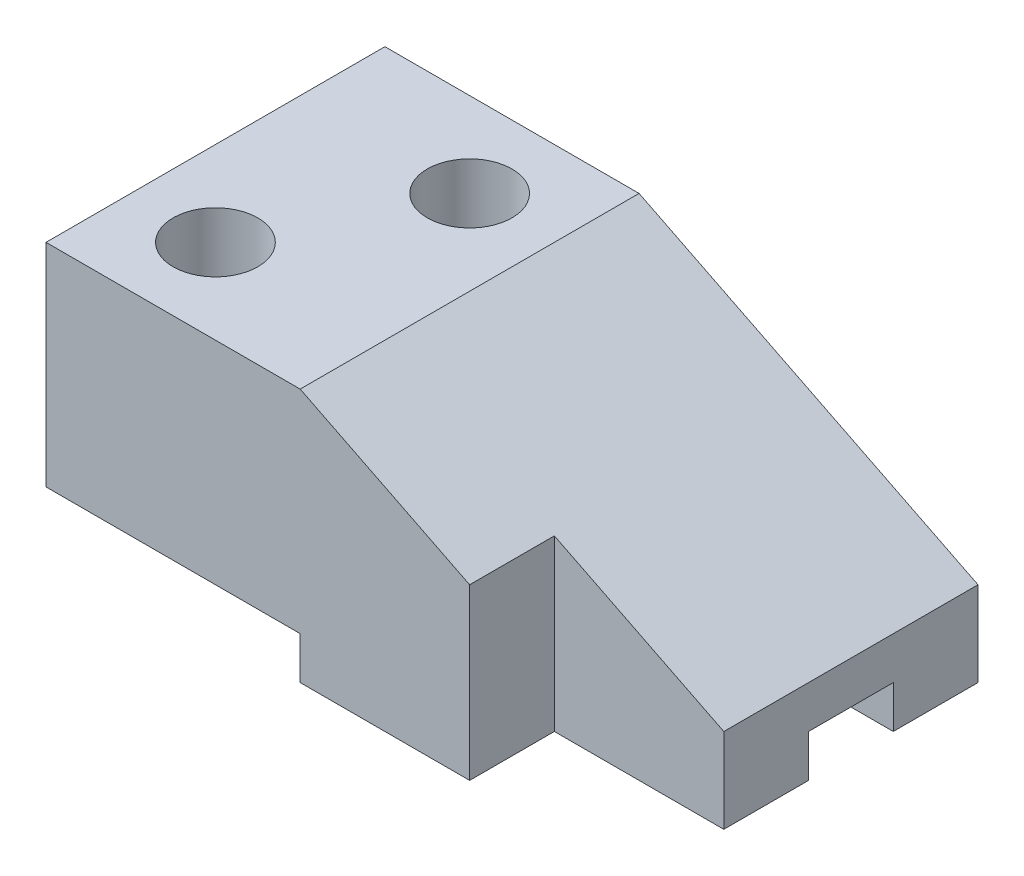
from build123d import *

# Parameters (mm, degrees)
SKETCH2_W           = 70
SKETCH2_H           = 40
BOSS_EXTRUDE1_DEPTH = 30
CUT_EXTRUDE2_DEPTH  = 49
SKETCH5_W           = 20
SKETCH5_H           = 10
CUT_EXTRUDE3_DEPTH  = 49
SKETCH6_W           = 40
SKETCH6_H           = 5
CUT_EXTRUDE4_DEPTH  = 30
SKETCH7_W           = 10
SKETCH7_H           = 5
CUT_EXTRUDE5_DEPTH  = 41
SKETCH8_R           = 5
CUT_EXTRUDE6_DEPTH  = 31
SKETCH9_R           = 5
CUT_EXTRUDE7_DEPTH  = 31


with BuildPart() as part:
    # Sketch2 → Boss-Extrude1 (new body)
    with BuildSketch(Plane(origin=(0, 0, 0), x_dir=(1, 0, 0), z_dir=(0, 1, 0))):
        with Locations((35, 20)):
            Rectangle(SKETCH2_W, SKETCH2_H)
    extrude(amount=BOSS_EXTRUDE1_DEPTH)

    # Sketch4 → Cut-Extrude2 (cut)
    with BuildSketch(Plane.XY):
        Polygon((70, 30), (30, 30), (70, 10), align=None)
    extrude(amount=-CUT_EXTRUDE2_DEPTH, mode=Mode.SUBTRACT)

    # Sketch5 → Cut-Extrude3 (cut)
    with BuildSketch(Plane(origin=(0, 0, 0), x_dir=(-1, 0, 0), z_dir=(0, -1, 0))):
        with Locations((-60, 5)):
            Rectangle(SKETCH5_W, SKETCH5_H)
    extrude(amount=-CUT_EXTRUDE3_DEPTH, mode=Mode.SUBTRACT)

    # Sketch6 → Cut-Extrude4 (cut)
    with BuildSketch(Plane.ZY):
        with Locations((-20, 2.5)):
            Rectangle(SKETCH6_W, SKETCH6_H)
    extrude(amount=-CUT_EXTRUDE4_DEPTH, mode=Mode.SUBTRACT)

    # Sketch7 → Cut-Extrude5 (cut, through all)
    with BuildSketch(Plane.ZY.offset(-30)):
        with Locations((-25, 2.5)):
            Rectangle(SKETCH7_W, SKETCH7_H)
    extrude(amount=-CUT_EXTRUDE5_DEPTH, mode=Mode.SUBTRACT)

    # Sketch8 → Cut-Extrude6 (cut, through all)
    with BuildSketch(Plane(origin=(0, 30, 0), x_dir=(1, 0, 0), z_dir=(0, 1, 0))):
        with Locations((10, 10)):
            Circle(SKETCH8_R)
    extrude(amount=-CUT_EXTRUDE6_DEPTH, mode=Mode.SUBTRACT)

    # Sketch9 → Cut-Extrude7 (cut, through all)
    with BuildSketch(Plane(origin=(0, 30, 0), x_dir=(1, 0, 0), z_dir=(0, 1, 0))):
        with Locations((20, 30)):
            Circle(SKETCH9_R)
    extrude(amount=-CUT_EXTRUDE7_DEPTH, mode=Mode.SUBTRACT)


solid = part.part
